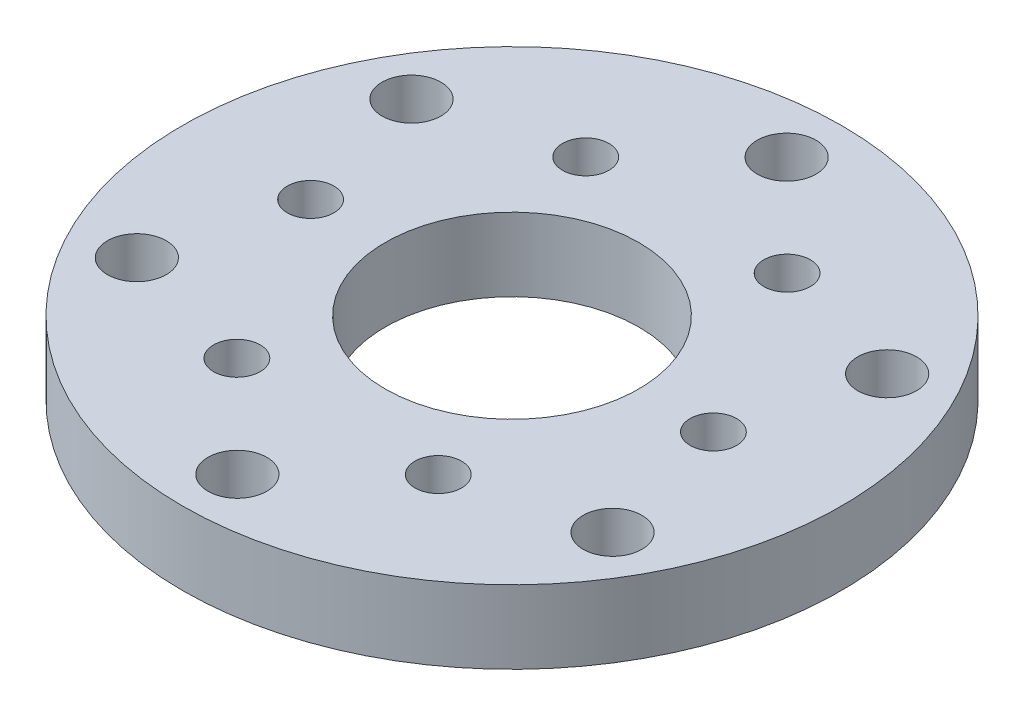
from build123d import *

# Parameters (mm, degrees)
SKETCH1_R               = 28.575
BOSS_EXTRUDE1_DEPTH     = 6.35
F_1_4_20_TAPPED_HOLE1_D = 5.1054
SKETCH5_R               = 11
CUT_EXTRUDE1_DEPTH      = 7.35
F_10_32_TAPPED_HOLE1_D  = 4.0386


with BuildPart() as part:
    # Sketch1 → Boss-Extrude1 (new body)
    with BuildSketch(Plane(origin=(0, 0, 0), x_dir=(1, 0, 0), z_dir=(0, 1, 0))):
        Circle(SKETCH1_R)
    extrude(amount=BOSS_EXTRUDE1_DEPTH)

    # 1/4-20 Tapped Hole1 (through all)
    with Locations(Plane(origin=(0, 6.35, 0), x_dir=(1, 0, 0), z_dir=(0, 1, 0))):
        with Locations((0, 23.8125), (20.622229928, 11.90625), (20.622229928, -11.90625), (0, -23.8125), (-20.622229928, -11.90625), (-20.622229928, 11.90625)):
            Hole(F_1_4_20_TAPPED_HOLE1_D / 2)

    # Sketch5 → Cut-Extrude1 (cut, through all)
    with BuildSketch(Plane(origin=(0, 6.35, 0), x_dir=(1, 0, 0), z_dir=(0, 1, 0))):
        Circle(SKETCH5_R)
    extrude(amount=-CUT_EXTRUDE1_DEPTH, mode=Mode.SUBTRACT)

    # #10-32 Tapped Hole1 (through all)
    with Locations(Plane(origin=(0, 6.35, 0), x_dir=(1, 0, 0), z_dir=(0, 1, 0))):
        with Locations((-8.73125, 15.122968614), (8.73125, 15.122968614), (17.4625, 0), (8.73125, -15.122968614), (-8.73125, -15.122968614), (-17.4625, 0)):
            Hole(F_10_32_TAPPED_HOLE1_D / 2)


solid = part.part
